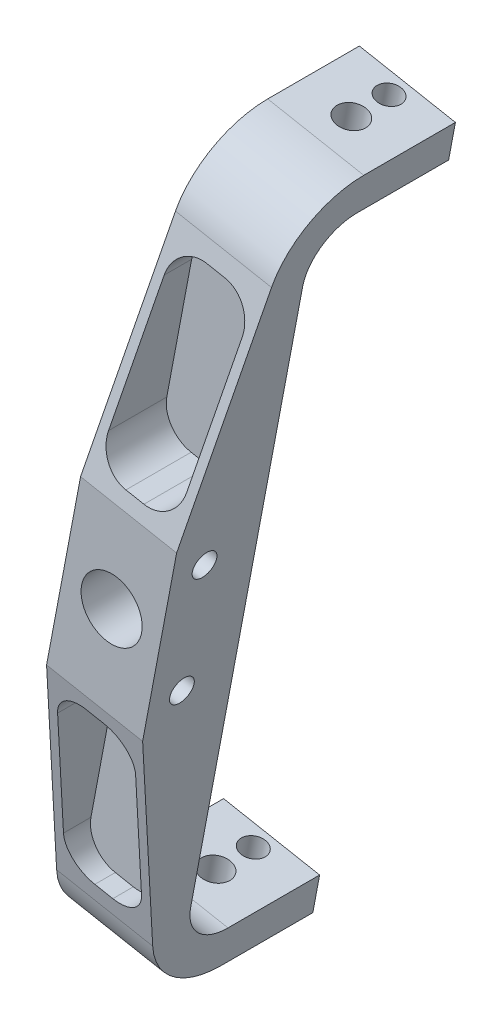
from build123d import *

# Parameters (mm, degrees)
SKETCH1_R               = 10
BOSS_EXTRUDE1_DEPTH     = 28.5
BOSS_EXTRUDE2_DEPTH     = 45
SKETCH4_R               = 4.7625
SKETCH4_R_2             = 3.96875
CUT_EXTRUDE1_DEPTH      = 258.595725096
FILLET3_R               = 15
SKETCH10_R              = 4
CUT_EXTRUDE2_DEPTH      = 78.869968284
CUT_EXTRUDE2_DEPTH_BACK = 46.869968284
CUT_EXTRUDE4_DEPTH      = 22.5


with BuildPart() as part:
    # Sketch1 → Boss-Extrude1 (new body)
    with BuildSketch(Plane.XY):
        Polygon((-7.617068705, -126.66669812), (39.062241625, 120.733646626), (7.617068705, 126.66669812), (-39.062241625, -120.733646626), align=None)
        Circle(SKETCH1_R, mode=Mode.SUBTRACT)
    extrude(amount=BOSS_EXTRUDE1_DEPTH)

    # Sketch2 → Boss-Extrude2 (add)
    with BuildSketch(Plane(origin=(0, 0, 0), x_dir=(-1, 0, 0), z_dir=(0, 0, -1))):
        Polygon((-39.062241625, 120.733646626), (-36.837347314, 108.941706781), (-5.392174394, 114.874758275), (-7.617068705, 126.66669812), align=None)
        Polygon((36.837347314, -108.941706781), (5.392174394, -114.874758275), (7.617068705, -126.66669812), (39.062241625, -120.733646626), align=None)
    extrude(amount=BOSS_EXTRUDE2_DEPTH)

    # Sketch4 → Cut-Extrude1 (cut, through all)
    with BuildSketch(Plane(origin=(-1.656161502, 128.416364197, 0), x_dir=(0.982661654, -0.185407859, 0), z_dir=(0.185407859, 0.982661654, 0))):
        with Locations((25.436849572, 26.64759704)):
            Circle(SKETCH4_R)
        with Locations((25.436849572, 39)):
            Circle(SKETCH4_R_2)
    extrude(amount=-CUT_EXTRUDE1_DEPTH, mode=Mode.SUBTRACT)

    # Fillet3
    fillet3_edges = [part.edges().sort_by_distance(p)[0] for p in [
        (21.114760854, 111.908232528, 0),
        (-21.114760854, -111.908232528, 0),
    ]]
    fillet(fillet3_edges, radius=FILLET3_R)

    # Sketch10 → Cut-Extrude2 (cut, two sides)
    with BuildSketch(Plane(origin=(-16.024269994, 1.367603019, 0), x_dir=(0, 0, -1), z_dir=(0.982661654, -0.185407859, 0))) as cut_extrude2_sk:
        with Locations((-17.5, 21.627134551)):
            Circle(SKETCH10_R)
        with Locations((-17.5, -18.372865449)):
            Circle(SKETCH10_R)
        with BuildLine():
            Line((-28.5, 31.627134551), (-11.316666773, 106.545885621))
            ThreePointArc((-11.316666773, 106.545885621), (-1.82302812, 121.628280107), (15, 127.509906002))
            Line((15, 127.509906002), (-44.768549469, 140.171550448))
            Line((-44.768549469, 140.171550448), (-46.912682998, 31.416920937))
            Line((-46.912682998, 31.416920937), (-28.5, 31.627134551))
        make_face()
        with BuildLine():
            Line((-44.768549469, -136.917281346), (15, -124.255636901))
            ThreePointArc((15, -124.255636901), (-1.82302812, -118.374011006), (-11.316666773, -103.29161652))
            Line((-11.316666773, -103.29161652), (-28.5, -28.372865449))
            Line((-28.5, -28.372865449), (-46.912682998, -28.162651835))
            Line((-46.912682998, -28.162651835), (-44.768549469, -136.917281346))
        make_face()
    extrude(amount=CUT_EXTRUDE2_DEPTH, mode=Mode.SUBTRACT)
    extrude(cut_extrude2_sk.sketch, amount=-CUT_EXTRUDE2_DEPTH_BACK, mode=Mode.SUBTRACT)

    # Sketch11 → Cut-Extrude4 (cut)
    with BuildSketch(Plane.XY.offset(28.5)):
        with BuildLine():
            Line((3.541290111, 34.949381459), (9.437260033, 33.836934304))
            ThreePointArc((9.437260033, 33.836934304), (16.92877427, 35.404052106), (21.117955163, 41.809472249))
            Line((21.117955163, 41.809472249), (29.254165873, 84.931389014))
            ThreePointArc((29.254165873, 84.931389014), (27.687048071, 92.422903251), (21.281627928, 96.612084144))
            Line((21.281627928, 96.612084144), (15.385658005, 97.724531299))
            ThreePointArc((15.385658005, 97.724531299), (7.894143769, 96.157413497), (3.704962876, 89.751993354))
            Line((3.704962876, 89.751993354), (-4.431247835, 46.630076588))
            ThreePointArc((-4.431247835, 46.630076588), (-2.864130032, 39.138562352), (3.541290111, 34.949381459))
        make_face()
        with BuildLine():
            Line((-21.281627928, -96.612084144), (-15.385658005, -97.724531299))
            ThreePointArc((-15.385658005, -97.724531299), (-7.894143769, -96.157413497), (-3.704962876, -89.751993354))
            Line((-3.704962876, -89.751993354), (4.431247835, -46.630076588))
            ThreePointArc((4.431247835, -46.630076588), (2.864130032, -39.138562352), (-3.541290111, -34.949381459))
            Line((-3.541290111, -34.949381459), (-9.437260033, -33.836934304))
            ThreePointArc((-9.437260033, -33.836934304), (-16.92877427, -35.404052106), (-21.117955163, -41.809472249))
            Line((-21.117955163, -41.809472249), (-29.254165873, -84.931389014))
            ThreePointArc((-29.254165873, -84.931389014), (-27.687048071, -92.422903251), (-21.281627928, -96.612084144))
        make_face()
    extrude(amount=-CUT_EXTRUDE4_DEPTH, mode=Mode.SUBTRACT)


solid = part.part
